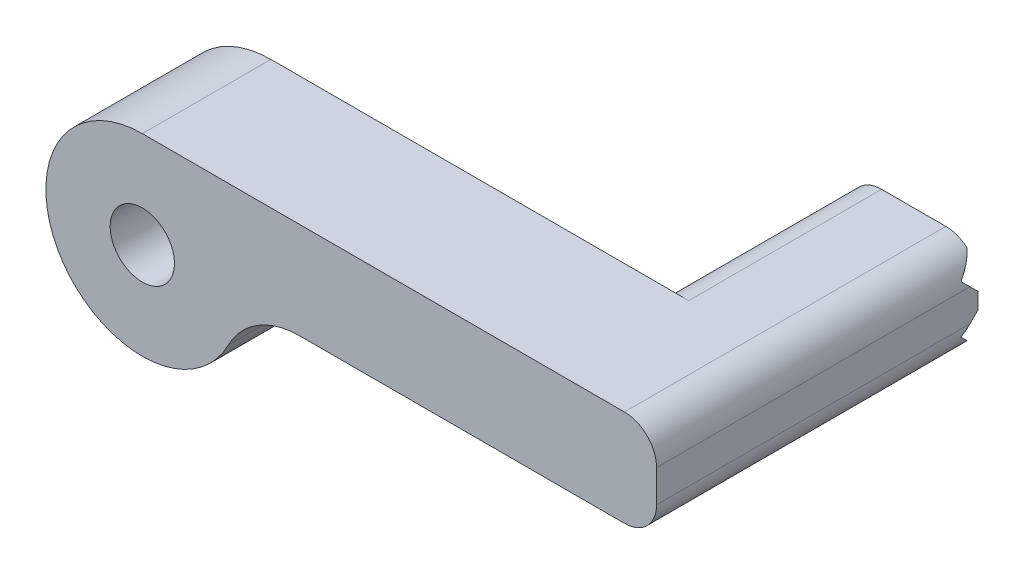
from build123d import *

# Parameters (mm, degrees)
BOSS_EXTRUDE1_DEPTH = 8
BOSS_EXTRUDE2_DEPTH = 12
SKETCH3_R           = 2
CUT_EXTRUDE1_DEPTH  = 8
FILLET1_R           = 2
CUT_EXTRUDE2_DEPTH  = 8


with BuildPart() as part:
    # Sketch1 → Boss-Extrude1 (new body)
    with BuildSketch(Plane.XY):
        with BuildLine():
            Line((-23.31623588, 68.971177363), (-23.31623588, 70.971177363))
            Line((-23.31623588, 70.971177363), (-55.31623588, 70.971177363))
            ThreePointArc((-55.31623588, 70.971177363), (-60.433053073, 61.837779556), (-49.971894623, 62.243904636))
            ThreePointArc((-49.971894623, 62.243904636), (-48.129441748, 64.23519169), (-45.518276909, 64.971177363))
            Line((-45.518276909, 64.971177363), (-23.31623588, 64.971177363))
            Line((-23.31623588, 64.971177363), (-23.31623588, 68.971177363))
        make_face()
    extrude(amount=BOSS_EXTRUDE1_DEPTH)

    # Sketch2 → Boss-Extrude2 (add)
    with BuildSketch(Plane.XY):
        Polygon((-23.31623588, 68.971177363), (-23.31623588, 70.971177363), (-31.31623588, 70.971177363), (-31.31623588, 67.971177363), (-31.31623588, 64.971177363), (-23.31623588, 64.971177363), align=None)
    extrude(amount=-BOSS_EXTRUDE2_DEPTH)

    # Sketch3 → Cut-Extrude1 (cut)
    with BuildSketch(Plane(origin=(0, 0, 0), x_dir=(-1, 0, 0), z_dir=(0, 0, -1))):
        with Locations((55.31623588, 64.971177363)):
            Circle(SKETCH3_R)
    extrude(amount=-CUT_EXTRUDE1_DEPTH, mode=Mode.SUBTRACT)

    # Fillet1
    fillet1_edges = [part.edges().sort_by_distance(p)[0] for p in [
        (-31.31623588, 70.971177363, -6),
        (-31.31623588, 64.971177363, -6),
        (-23.31623588, 64.971177363, -2),
        (-23.31623588, 70.971177363, -2),
    ]]
    fillet(fillet1_edges, radius=FILLET1_R)

    # Sketch4 → Cut-Extrude2 (cut)
    with BuildSketch(Plane.ZY.offset(31.31623588)):
        Polygon((-12, 70.971177363), (-13, 70.971177363), (-13, 64.971177363), (-12, 64.971177363), (-12, 65.471177363), (-11, 66.471177363), (-12, 67.471177363), (-12, 68.471177363), (-11, 69.471177363), (-12, 70.471177363), align=None)
    extrude(amount=-CUT_EXTRUDE2_DEPTH, mode=Mode.SUBTRACT)


solid = part.part
